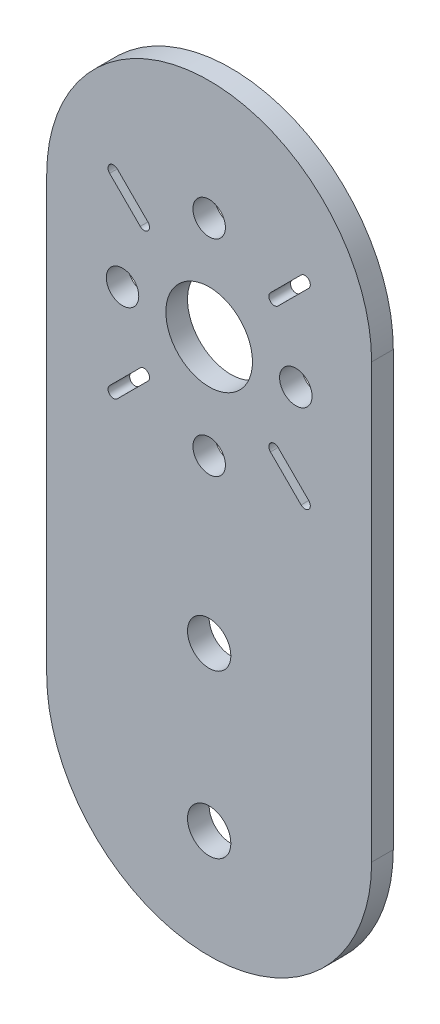
from build123d import *

# Parameters (mm, degrees)
SKETCH1_R           = 2
SKETCH1_R_2         = 1.5
SKETCH1_R_3         = 4
BOSS_EXTRUDE1_DEPTH = 2


with BuildPart() as part:
    # Sketch1 → Boss-Extrude1 (new body)
    with BuildSketch(Plane.XY):
        with BuildLine():
            Line((-15, 20), (-15, -20))
            ThreePointArc((-15, -20), (0, -35), (15, -20))
            Line((15, -20), (15, 20))
            ThreePointArc((15, 20), (0, 35), (-15, 20))
        make_face()
        with Locations((0, -25)):
            Circle(SKETCH1_R, mode=Mode.SUBTRACT)
        with Locations((0, -10)):
            Circle(SKETCH1_R, mode=Mode.SUBTRACT)
        with Locations((0, 5)):
            Circle(SKETCH1_R_2, mode=Mode.SUBTRACT)
        with Locations((0, 24)):
            Circle(SKETCH1_R_2, mode=Mode.SUBTRACT)
        with Locations((-8, 14.5)):
            Circle(SKETCH1_R_2, mode=Mode.SUBTRACT)
        with Locations((8, 14.5)):
            Circle(SKETCH1_R_2, mode=Mode.SUBTRACT)
        with Locations((0, 14.5)):
            Circle(SKETCH1_R_3, mode=Mode.SUBTRACT)
        with BuildLine():
            Line((5.656854249, 8.136038969), (8.485281374, 5.307611845))
            ThreePointArc((8.485281374, 5.307611845), (9.192388155, 5.307611845), (9.192388155, 6.014718626))
            Line((9.192388155, 6.014718626), (6.363961031, 8.843145751))
            ThreePointArc((6.363961031, 8.843145751), (5.656854249, 8.843145751), (5.656854249, 8.136038969))
        make_face(mode=Mode.SUBTRACT)
        with BuildLine():
            Line((-6.363961031, 8.843145751), (-9.192388155, 6.014718626))
            ThreePointArc((-9.192388155, 6.014718626), (-9.192388155, 5.307611845), (-8.485281374, 5.307611845))
            Line((-8.485281374, 5.307611845), (-5.656854249, 8.136038969))
            ThreePointArc((-5.656854249, 8.136038969), (-5.656854249, 8.843145751), (-6.363961031, 8.843145751))
        make_face(mode=Mode.SUBTRACT)
        with BuildLine():
            Line((6.363961031, 20.156854249), (9.192388155, 22.985281374))
            ThreePointArc((9.192388155, 22.985281374), (9.192388155, 23.692388155), (8.485281374, 23.692388155))
            Line((8.485281374, 23.692388155), (5.656854249, 20.863961031))
            ThreePointArc((5.656854249, 20.863961031), (5.656854249, 20.156854249), (6.363961031, 20.156854249))
        make_face(mode=Mode.SUBTRACT)
        with BuildLine():
            Line((-5.656854249, 20.863961031), (-8.485281374, 23.692388155))
            ThreePointArc((-8.485281374, 23.692388155), (-9.192388155, 23.692388155), (-9.192388155, 22.985281374))
            Line((-9.192388155, 22.985281374), (-6.363961031, 20.156854249))
            ThreePointArc((-6.363961031, 20.156854249), (-5.656854249, 20.156854249), (-5.656854249, 20.863961031))
        make_face(mode=Mode.SUBTRACT)
    extrude(amount=BOSS_EXTRUDE1_DEPTH)


solid = part.part
